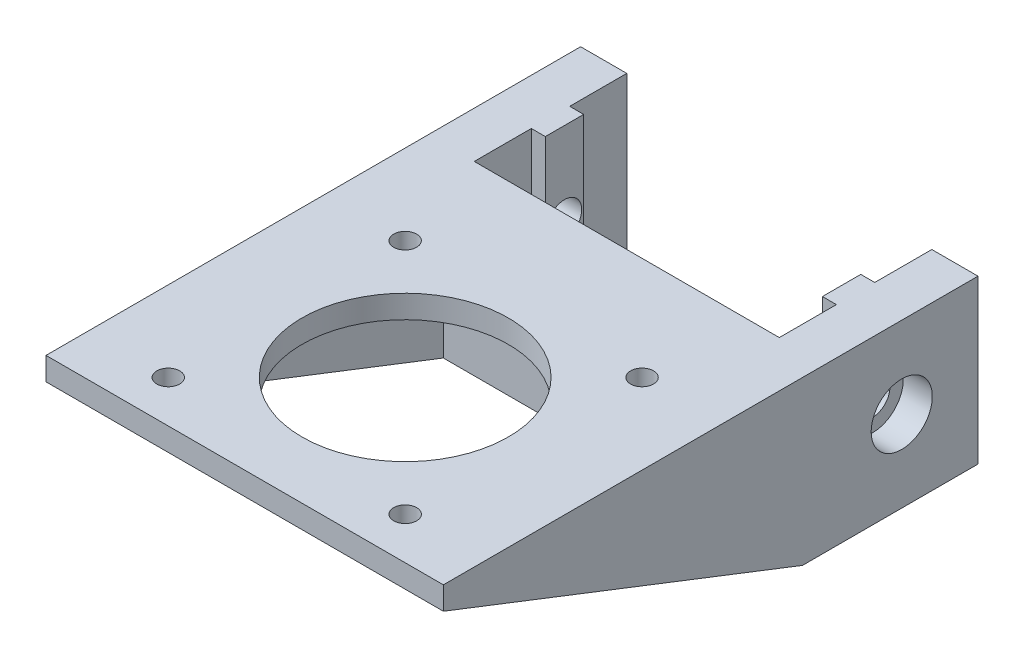
from build123d import *

# Parameters (mm, degrees)
SKETCH1_W           = 42
SKETCH1_H           = 21.3
BOSS_EXTRUDE1_DEPTH = 3
SKETCH2_R           = 3
CUT_EXTRUDE1_DEPTH  = 3
SKETCH4_W           = 42
SKETCH4_H           = 50
SKETCH4_R           = 1.5
SKETCH4_R_2         = 13.5
BOSS_EXTRUDE2_DEPTH = 3
BOSS_EXTRUDE3_DEPTH = 5
BOSS_EXTRUDE4_START = -42
BOSS_EXTRUDE4_DEPTH = 5
SKETCH6_W           = 6.04
SKETCH6_H           = 19.96
BOSS_EXTRUDE5_DEPTH = 21.3
SKETCH8_W           = 1.829995551
SKETCH8_H           = 5.02
BOSS_EXTRUDE6_DEPTH = 21.3
SKETCH7_R           = 2.25
CUT_EXTRUDE2_DEPTH  = 10
SKETCH9_R           = 4
CUT_EXTRUDE3_DEPTH  = 3.8


with BuildPart() as part:
    # Sketch1 → Boss-Extrude1 (new body)
    with BuildSketch(Plane.XY):
        with Locations((98.144783915, 168.215968794)):
            Rectangle(SKETCH1_W, SKETCH1_H)
    extrude(amount=BOSS_EXTRUDE1_DEPTH)

    # Sketch2 → Cut-Extrude1 (cut)
    with BuildSketch(Plane.XY.offset(3)):
        with Locations((108.644783915, 166.065968794)):
            Circle(SKETCH2_R)
        with Locations((88.644783915, 166.065968794)):
            Circle(SKETCH2_R)
    extrude(amount=-CUT_EXTRUDE1_DEPTH, mode=Mode.SUBTRACT)

    # Sketch4 → Boss-Extrude2 (add)
    with BuildSketch(Plane(origin=(0, 178.865968794, 0), x_dir=(-1, 0, 0), z_dir=(0, 1, 0))):
        with Locations((-98.144783915, 25)):
            Rectangle(SKETCH4_W, SKETCH4_H)
        with Locations((-113.644783915, 44.500179206)):
            Circle(SKETCH4_R, mode=Mode.SUBTRACT)
        with Locations((-82.644783915, 44.500179206)):
            Circle(SKETCH4_R, mode=Mode.SUBTRACT)
        with Locations((-82.644783915, 13.500179206)):
            Circle(SKETCH4_R, mode=Mode.SUBTRACT)
        with Locations((-113.644783915, 13.500179206)):
            Circle(SKETCH4_R, mode=Mode.SUBTRACT)
        with Locations((-98.144783915, 29.000179206)):
            Circle(SKETCH4_R_2, mode=Mode.SUBTRACT)
    extrude(amount=-BOSS_EXTRUDE2_DEPTH)

    # Sketch5 → Boss-Extrude3 (add)
    with BuildSketch(Plane(origin=(119.144783915, 0, 0), x_dir=(0, 0, -1), z_dir=(1, 0, 0))):
        Polygon((0, 157.565968794), (0, 178.865968794), (-50, 178.865968794), (-50, 175.865968794), (-3, 157.565968794), align=None)
    extrude(amount=BOSS_EXTRUDE3_DEPTH)

    # Sketch5_3 → Boss-Extrude4 (add)
    with BuildSketch(Plane(origin=(119.144783915, 0, 0), x_dir=(0, 0, -1), z_dir=(1, 0, 0)).offset(BOSS_EXTRUDE4_START)):
        Polygon((0, 157.565968794), (0, 178.865968794), (-50, 178.865968794), (-50, 175.865968794), (-3, 157.565968794), align=None)
    extrude(amount=-BOSS_EXTRUDE4_DEPTH)

    # Sketch6 → Boss-Extrude5 (add)
    with BuildSketch(Plane(origin=(0, 178.865968794, 0), x_dir=(1, 0, 0), z_dir=(0, 1, 0))):
        with Locations((75.164783915, 9.98)):
            Rectangle(SKETCH6_W, SKETCH6_H)
    boss_extrude5 = extrude(amount=-BOSS_EXTRUDE5_DEPTH)

    # Sketch8 → Boss-Extrude6 (add)
    with BuildSketch(Plane(origin=(0, 157.565968794, 0), x_dir=(-1, 0, 0), z_dir=(0, -1, 0))):
        with Locations((-79.099781691, 9.98)):
            Rectangle(SKETCH8_W, SKETCH8_H)
    boss_extrude6 = extrude(amount=-BOSS_EXTRUDE6_DEPTH)

    # Sketch7 → Cut-Extrude2 (cut)
    with BuildSketch(Plane.ZY.offset(-72.144783915)):
        with Locations((-9.98, 168.215968794)):
            Circle(SKETCH7_R)
    cut_extrude2 = extrude(amount=-CUT_EXTRUDE2_DEPTH, mode=Mode.SUBTRACT)

    # Sketch9 → Cut-Extrude3 (cut)
    with BuildSketch(Plane.ZY.offset(-72.144783915)):
        with Locations((-9.98, 168.215968794)):
            Circle(SKETCH9_R)
    cut_extrude3 = extrude(amount=-CUT_EXTRUDE3_DEPTH, mode=Mode.SUBTRACT)

    # Mirror1: Boss-Extrude5, Boss-Extrude6, Cut-Extrude2, Cut-Extrude3 across plane
    add(boss_extrude5.mirror(Plane.ZY.offset(-98.144783915)))
    add(boss_extrude6.mirror(Plane.ZY.offset(-98.144783915)))
    add(cut_extrude2.mirror(Plane.ZY.offset(-98.144783915)), mode=Mode.SUBTRACT)
    add(cut_extrude3.mirror(Plane.ZY.offset(-98.144783915)), mode=Mode.SUBTRACT)


solid = part.part
